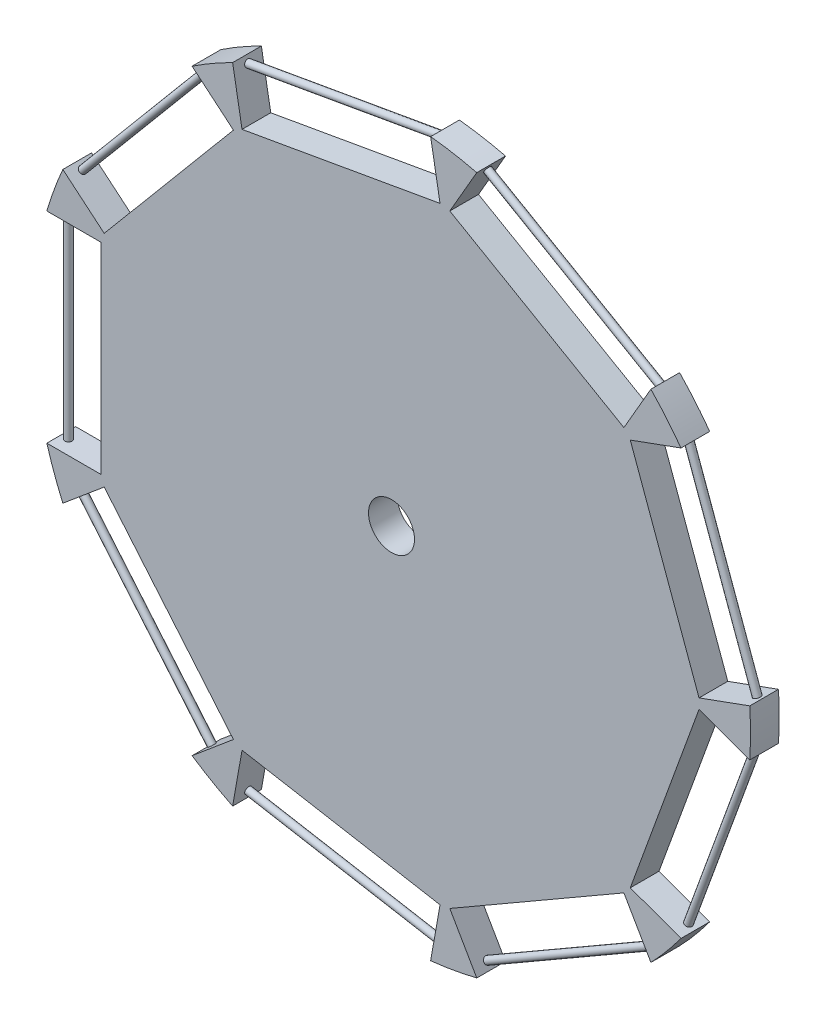
from build123d import *

# Parameters (mm, degrees)
SKETCH1_R           = 50
BOSS_EXTRUDE1_DEPTH = 4
SKETCH2_W           = 6.3
SKETCH2_H           = 28
CUT_EXTRUDE1_DEPTH  = 4
SKETCH5_W           = 0.4
SKETCH5_H           = 28
CUT_EXTRUDE2_DEPTH  = 1.8
SKETCH7_W           = 0.4
SKETCH7_H           = 28
CUT_EXTRUDE3_DEPTH  = 1.8
SKETCH8_W           = 0.5
SKETCH8_H           = 28
SKETCH9_W           = 0.5
SKETCH9_H           = 28
SKETCH10_W          = 28
SKETCH10_H          = 0.5
SKETCH11_W          = 28
SKETCH11_H          = 0.5
SKETCH12_W          = 0.5
SKETCH12_H          = 28
SKETCH13_W          = 0.5
SKETCH13_H          = 28
SKETCH14_W          = 28
SKETCH14_H          = 0.5
SKETCH15_W          = 0.5
SKETCH15_H          = 28
SKETCH16_W          = 28
SKETCH16_H          = 0.5
SKETCH17_R          = 3.2
CUT_EXTRUDE4_DEPTH  = 10


with BuildPart() as part:
    # Sketch1 → Boss-Extrude1 (new body)
    with BuildSketch(Plane.XY):
        Circle(SKETCH1_R)
    extrude(amount=BOSS_EXTRUDE1_DEPTH)

    # Sketch2 → Cut-Extrude1 (cut)
    with BuildSketch(Plane.XY.offset(4)):
        Polygon((5.663242619, 48.504941857), (6.757226139, 42.300653013), (-20.817390946, 37.438504038), (-21.911374465, 43.642792882), align=None)
        with BuildLine():
            Line((5.593783348, 48.898864958), (5.452196014, 49.701846632))
            ThreePointArc((5.452196014, 49.701846632), (-8.682408883, 49.240387651), (-22.12242107, 44.839697657))
            Line((-22.12242107, 44.839697657), (-21.980833736, 44.036715983))
            Line((-21.980833736, 44.036715983), (5.593783348, 48.898864958))
        make_face()
        Polygon((35.516671173, 33.516678987), (32.366671173, 28.060718943), (8.117959867, 42.060718943), (11.267959867, 47.516678987), align=None)
        Polygon((33.254827036, 27.002256002), (42.831391049, 0.69086262), (48.75145456, 2.845589522), (39.174890547, 29.156982905), align=None)
        with BuildLine():
            Line((40.316963791, 29.572663571), (39.550767596, 29.293790962))
            Line((39.550767596, 29.293790962), (49.127331609, 2.98239758))
            Line((49.127331609, 2.98239758), (49.893527804, 3.261270189))
            ThreePointArc((49.893527804, 3.261270189), (46.984631039, 17.101007166), (40.316963791, 29.572663571))
        make_face()
        with BuildLine():
            ThreePointArc((40.316963791, -29.572663571), (46.984631039, -17.101007166), (49.893527804, -3.261270189))
            Line((49.893527804, -3.261270189), (49.127331609, -2.98239758))
            Line((49.127331609, -2.98239758), (39.550767596, -29.293790962))
            Line((39.550767596, -29.293790962), (40.316963791, -29.572663571))
        make_face()
        Polygon((32.366671173, -28.060718943), (8.117959867, -42.060718943), (11.267959867, -47.516678987), (35.516671173, -33.516678987), align=None)
        with BuildLine():
            ThreePointArc((-22.12242107, -44.839697657), (-8.682408883, -49.240387651), (5.452196014, -49.701846632))
            Line((5.452196014, -49.701846632), (5.593783348, -48.898864958))
            Line((5.593783348, -48.898864958), (-21.980833736, -44.036715983))
            Line((-21.980833736, -44.036715983), (-22.12242107, -44.839697657))
        make_face()
        Polygon((6.757226139, -42.300653013), (-20.817390946, -37.438504038), (-21.911374465, -43.642792882), (5.663242619, -48.504941857), align=None)
        with BuildLine():
            Line((-45.144550944, -19.605073996), (-45.769159805, -20.129183061))
            ThreePointArc((-45.769159805, -20.129183061), (-38.302222156, -32.139380484), (-27.771106734, -41.578427469))
            Line((-27.771106734, -41.578427469), (-27.146497873, -41.054318403))
            Line((-27.146497873, -41.054318403), (-45.144550944, -19.605073996))
        make_face()
        Polygon((-44.838133167, -19.347958952), (-40.012053175, -15.298397011), (-22.014000104, -36.747641418), (-26.840080095, -40.797203359), align=None)
        with BuildLine():
            Line((-47.184631039, 14), (-48, 14))
            ThreePointArc((-48, 14), (-50, 0), (-48, -14))
            Line((-48, -14), (-47.184631039, -14))
            Line((-47.184631039, -14), (-47.184631039, 14))
        make_face()
        with Locations((-43.634631039, 0)):
            Rectangle(SKETCH2_W, SKETCH2_H)
        Polygon((-26.840080095, 40.797203359), (-22.014000104, 36.747641418), (-40.012053175, 15.298397011), (-44.838133167, 19.347958952), align=None)
        with BuildLine():
            Line((-27.146497873, 41.054318403), (-27.771106734, 41.578427469))
            ThreePointArc((-27.771106734, 41.578427469), (-38.302222156, 32.139380484), (-45.769159805, 20.129183061))
            Line((-45.769159805, 20.129183061), (-45.144550944, 19.605073996))
            Line((-45.144550944, 19.605073996), (-27.146497873, 41.054318403))
        make_face()
        with BuildLine():
            ThreePointArc((36.124355653, 34.569219382), (25, 43.301270189), (11.875644347, 48.569219382))
            Line((11.875644347, 48.569219382), (11.467959867, 47.863089148))
            Line((11.467959867, 47.863089148), (35.716671173, 33.863089148))
            Line((35.716671173, 33.863089148), (36.124355653, 34.569219382))
        make_face()
        Polygon((42.831391049, -0.69086262), (33.254827036, -27.002256002), (39.174890547, -29.156982905), (48.75145456, -2.845589522), align=None)
        with BuildLine():
            Line((11.467959867, -47.863089148), (35.716671173, -33.863089148))
            Line((35.716671173, -33.863089148), (36.124355653, -34.569219382))
            ThreePointArc((36.124355653, -34.569219382), (25, -43.301270189), (11.875644347, -48.569219382))
            Line((11.875644347, -48.569219382), (11.467959867, -47.863089148))
        make_face()
    extrude(amount=-CUT_EXTRUDE1_DEPTH, mode=Mode.SUBTRACT)

    # Sketch5 → Cut-Extrude2 (cut)
    with BuildSketch(Plane.XY.offset(4)):
        Polygon((39.174890547, 29.156982905), (39.550767596, 29.293790962), (49.127331609, 2.98239758), (48.75145456, 2.845589522), align=None)
        Polygon((39.174890547, -29.156982905), (39.550767596, -29.293790962), (49.127331609, -2.98239758), (48.75145456, -2.845589522), align=None)
        Polygon((11.267959867, -47.516678987), (11.467959867, -47.863089148), (35.716671173, -33.863089148), (35.516671173, -33.516678987), align=None)
        Polygon((-21.911374465, -43.642792882), (-21.980833736, -44.036715983), (5.593783348, -48.898864958), (5.663242619, -48.504941857), align=None)
        Polygon((-27.146497873, -41.054318403), (-26.840080095, -40.797203359), (-44.838133167, -19.347958952), (-45.144550944, -19.605073996), align=None)
        with Locations((-46.984631039, 0)):
            Rectangle(SKETCH5_W, SKETCH5_H)
        Polygon((-45.144550944, 19.605073996), (-44.838133167, 19.347958952), (-26.840080095, 40.797203359), (-27.146497873, 41.054318403), align=None)
        Polygon((-21.980833736, 44.036715983), (-21.911374465, 43.642792882), (5.663242619, 48.504941857), (5.593783348, 48.898864958), align=None)
        Polygon((11.267959867, 47.516678987), (11.467959867, 47.863089148), (35.716671173, 33.863089148), (35.516671173, 33.516678987), align=None)
    extrude(amount=-CUT_EXTRUDE2_DEPTH, mode=Mode.SUBTRACT)

    # Sketch7 → Cut-Extrude3 (cut)
    with BuildSketch(Plane(origin=(0, 0, 0), x_dir=(-1, 0, 0), z_dir=(0, 0, -1))):
        with Locations((46.984631039, 0)):
            Rectangle(SKETCH7_W, SKETCH7_H)
        Polygon((44.838133167, -19.347958952), (45.144550944, -19.605073996), (27.146497873, -41.054318403), (26.840080095, -40.797203359), align=None)
        Polygon((21.911374465, -43.642792882), (21.980833736, -44.036715983), (-5.593783348, -48.898864958), (-5.663242619, -48.504941857), align=None)
        Polygon((-11.267959867, -47.516678987), (-11.467959867, -47.863089148), (-35.716671173, -33.863089148), (-35.516671173, -33.516678987), align=None)
        Polygon((-39.174890547, -29.156982905), (-39.550767596, -29.293790962), (-49.127331609, -2.98239758), (-48.75145456, -2.845589522), align=None)
        Polygon((-48.75145456, 2.845589522), (-49.127331609, 2.98239758), (-39.550767596, 29.293790962), (-39.174890547, 29.156982905), align=None)
        Polygon((-35.716671173, 33.863089148), (-11.467959867, 47.863089148), (-11.267959867, 47.516678987), (-35.516671173, 33.516678987), align=None)
        Polygon((-5.593783348, 48.898864958), (-5.663242619, 48.504941857), (21.911374465, 43.642792882), (21.980833736, 44.036715983), align=None)
        Polygon((27.146497873, 41.054318403), (26.840080095, 40.797203359), (44.838133167, 19.347958952), (45.144550944, 19.605073996), align=None)
    extrude(amount=-CUT_EXTRUDE3_DEPTH, mode=Mode.SUBTRACT)

    # Sketch8 → Revolve1 (revolve)
    with BuildSketch(Plane.ZY.offset(46.984631039)):
        with Locations((2.25, 0)):
            Rectangle(SKETCH8_W, SKETCH8_H)
    revolve(axis=Axis((-46.984631039, 14, 2), (0, -1, 0)))

    # Sketch9 → Revolve2 (revolve)
    with BuildSketch(Plane(origin=(-35.99231552, 30.201138678, 0), x_dir=(0, 0, 1), z_dir=(-0.766044443, 0.64278761, 0))):
        with Locations((2.25, 0)):
            Rectangle(SKETCH9_W, SKETCH9_H)
    revolve(axis=Axis((-26.993288984, 40.925760881, 2), (-0.64278761, -0.766044443, 0)))

    # Sketch10 → Revolve3 (revolve)
    with BuildSketch(Plane(origin=(-8.158795558, 46.27082892, 0), x_dir=(0.984807753, 0.173648178, 0), z_dir=(-0.173648178, 0.984807753, 0))):
        with Locations((0, -1.75)):
            Rectangle(SKETCH10_W, SKETCH10_H)
    revolve(axis=Axis((-21.9461041, 43.839754433, 2), (0.984807753, 0.173648178, 0)))

    # Sketch11 → Revolve4 (revolve)
    with BuildSketch(Plane(origin=(23.49231552, 40.689884067, 0), x_dir=(0.866025404, -0.5, 0), z_dir=(0.5, 0.866025404, 0))):
        with Locations((0, -1.75)):
            Rectangle(SKETCH11_W, SKETCH11_H)
    revolve(axis=Axis((11.367959867, 47.689884067, 2), (0.866025404, -0.5, 0)))

    # Sketch12 → Revolve5 (revolve)
    with BuildSketch(Plane(origin=(44.151111078, 16.069690242, 0), x_dir=(0, 0, -1), z_dir=(0.939692621, 0.342020143, 0))):
        with Locations((-1.75, 0)):
            Rectangle(SKETCH12_W, SKETCH12_H)
    revolve(axis=Axis((39.362829071, 29.225386933, 2), (0.342020143, -0.939692621, 0)))

    # Sketch13 → Revolve6 (revolve)
    with BuildSketch(Plane(origin=(44.151111078, -16.069690242, 0), x_dir=(0, 0, -1), z_dir=(0.939692621, -0.342020143, 0))):
        with Locations((-1.75, 0)):
            Rectangle(SKETCH13_W, SKETCH13_H)
    revolve(axis=Axis((48.939393085, -2.913993551, 2), (-0.342020143, -0.939692621, 0)))

    # Sketch14 → Revolve7 (revolve)
    with BuildSketch(Plane(origin=(23.49231552, -40.689884067, 0), x_dir=(-0.866025404, -0.5, 0), z_dir=(0.5, -0.866025404, 0))):
        with Locations((0, -2.25)):
            Rectangle(SKETCH14_W, SKETCH14_H)
    revolve(axis=Axis((11.367959867, -47.689884067, 2), (0.866025404, 0.5, 0)))

    # Sketch15 → Revolve8 (revolve)
    with BuildSketch(Plane(origin=(-35.99231552, -30.201138678, 0), x_dir=(0, 0, 1), z_dir=(-0.766044443, -0.64278761, 0))):
        with Locations((2.25, 0)):
            Rectangle(SKETCH15_W, SKETCH15_H)
    revolve(axis=Axis((-44.991342055, -19.476516474, 2), (0.64278761, -0.766044443, 0)))

    # Sketch16 → Revolve9 (revolve)
    with BuildSketch(Plane(origin=(-8.158795558, -46.27082892, 0), x_dir=(-0.984807753, 0.173648178, 0), z_dir=(-0.173648178, -0.984807753, 0))):
        with Locations((0, -1.75)):
            Rectangle(SKETCH16_W, SKETCH16_H)
    revolve(axis=Axis((5.628512984, -48.701903407, 2), (-0.984807753, 0.173648178, 0)))

    # Sketch17 → Cut-Extrude4 (cut)
    with BuildSketch(Plane(origin=(0, 0, 0), x_dir=(-1, 0, 0), z_dir=(0, 0, -1))):
        Circle(SKETCH17_R)
    extrude(amount=-CUT_EXTRUDE4_DEPTH, mode=Mode.SUBTRACT)


solid = part.part
